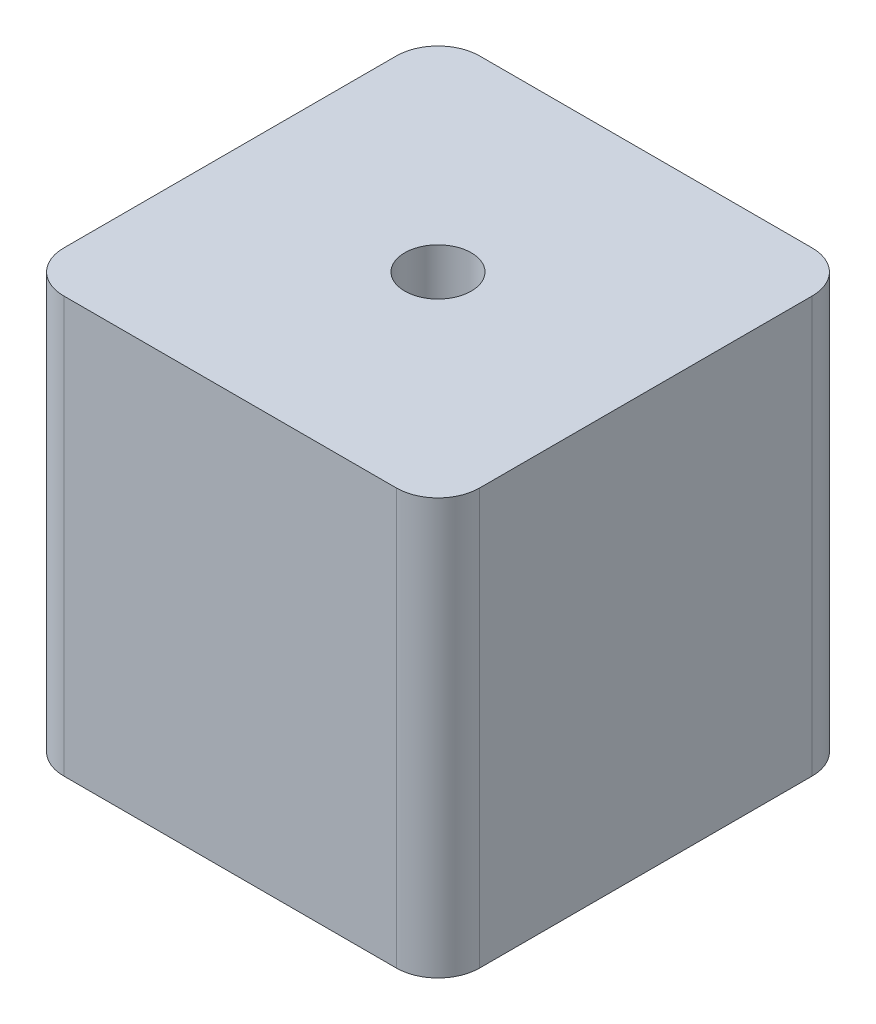
from build123d import *

# Parameters (mm, degrees)
SKETCH_1_W      = 20
SKETCH_1_H      = 20
SKETCH_1_R      = 1.6
EXTRUDE_1_DEPTH = 20
FILLET_1_R      = 2


with BuildPart() as part:
    # 草图1 → 凸台-拉伸1 (new body)
    with BuildSketch(Plane(origin=(0, 0, 0), x_dir=(1, 0, 0), z_dir=(0, 1, 0))):
        Rectangle(SKETCH_1_W, SKETCH_1_H)
        Circle(SKETCH_1_R, mode=Mode.SUBTRACT)
    extrude(amount=EXTRUDE_1_DEPTH)

    # 圆角1
    fillet_1_edges = [part.edges().sort_by_distance(p)[0] for p in [
        (10, 10, 10),
        (-10, 10, 10),
        (-10, 10, -10),
        (10, 10, -10),
    ]]
    fillet(fillet_1_edges, radius=FILLET_1_R)


solid = part.part
